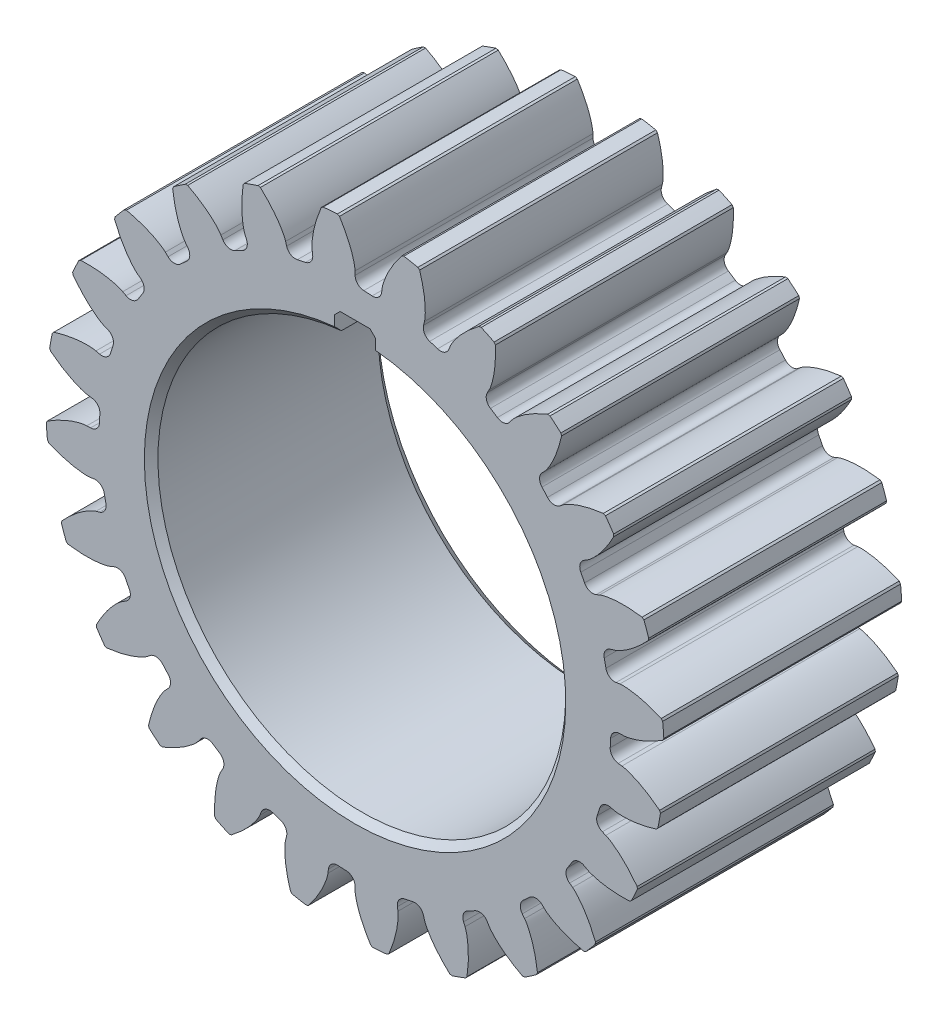
from build123d import *

# Parameters (mm, degrees)
SKETCH1_R                    = 37.625
BOSS_EXTRUDE1_DEPTH          = 35
BOSS_EXTRUDE2_DEPTH          = 35
CHAMFER1_SIZE                = 0.2
CIRPATTERN1_COUNT            = 24
CHAMFER1_OF_CIRPATTERN1_SIZE = 0.2
CUT_EXTRUDE1_DEPTH           = 35
CHAMFER2_SIZE                = 1
CHAMFER3_SIZE                = 1.6
CHAMFER4_SIZE                = 0.8


with BuildPart() as part:
    # Sketch1 → Boss-Extrude1 (new body)
    with BuildSketch(Plane.XY):
        Circle(SKETCH1_R)
    extrude(amount=BOSS_EXTRUDE1_DEPTH)

    # Sketch2 → Boss-Extrude2 (add)
    with BuildSketch(Plane.XY):
        with BuildLine():
            Line((39.4671, 0), (38.912317076, -0.008216426))
            ThreePointArc((38.912317076, -0.008216426), (38.000796603, -0.388472211), (37.602797274, -1.292386237))
            ThreePointArc((37.602797274, -1.292386237), (37.503596186, 3.020082466), (36.911446591, 7.292855106))
            ThreePointArc((36.911446591, 7.292855106), (37.448959809, 6.464275856), (38.409582275, 6.234779642))
            Line((38.409582275, 6.234779642), (38.9585311, 6.315444315))
            add(Edge.make_bspline(
                [(38.9585311, 6.315444315), (38.972678047, 6.317523123), (39.012450629, 6.322704621), (39.087997947, 6.329935202), (39.211681446, 6.33807843), (39.369801706, 6.34307574), (39.5746409, 6.343348403), (39.816411939, 6.335708833), (40.082432074, 6.31896913), (40.372020808, 6.291755537), (40.660942325, 6.256649221), (40.949040892, 6.214231715), (41.23584592, 6.165309201), (41.582899983, 6.098184264), (41.998464173, 6.006768216), (42.482973762, 5.884052997), (43.030761322, 5.726190055), (43.586701733, 5.545432212), (44.131652408, 5.351268244), (44.617289264, 5.160827267), (44.955266967, 5.020725261), (45.162237069, 4.931127491), (45.235496411, 4.898965653)],
                knots=[0, 0, 0, 0, 0, 0.005376749, 0.015083688, 0.02853182, 0.04661014, 0.064854849, 0.092110525, 0.119476176, 0.146842496, 0.174208854, 0.201574956, 0.228941013, 0.256307345, 0.307035032, 0.361767352, 0.416499661, 0.471231937, 0.525964282, 0.580696616, 0.610620377, 0.610620377, 0.610620377, 0.610620377, 0.610620377], degree=4))
            ThreePointArc((45.235496411, 4.898965653), (45.353186086, 3.65219275), (45.436518988, 2.402653171))
            add(Edge.make_bspline(
                [(39.4671, 0), (39.481397298, 0.000211745), (39.521486507, 0.001461342), (39.597217354, 0.006412861), (39.720610143, 0.018166145), (39.877492541, 0.038535309), (40.079735829, 0.071044107), (40.317168963, 0.11727294), (40.577082538, 0.176364932), (40.858584999, 0.249567249), (41.138165863, 0.330453816), (41.41576446, 0.418425677), (41.691045268, 0.512611732), (42.022886035, 0.634406582), (42.418467099, 0.791142382), (42.877096712, 0.989806535), (43.392564635, 1.233291113), (43.912416757, 1.500680173), (44.419275535, 1.779544052), (44.868180552, 2.04524164), (45.179384274, 2.237620804), (45.36935013, 2.359182957), (45.436518988, 2.402653171)],
                knots=[0, 0, 0, 0, 0, 0.005376749, 0.015083688, 0.02853182, 0.04661014, 0.064854849, 0.092110525, 0.119476176, 0.146842496, 0.174208854, 0.201574956, 0.228941013, 0.256307345, 0.307035032, 0.361767352, 0.416499661, 0.471231937, 0.525964282, 0.580696616, 0.610620377, 0.610620377, 0.610620377, 0.610620377, 0.610620377], degree=4))
        make_face()
    boss_extrude2 = extrude(amount=BOSS_EXTRUDE2_DEPTH)

    # Chamfer1
    chamfer1_edges = [part.edges().sort_by_distance(p)[0] for p in [
        (45.436518988, 2.402653171, 17.5),
        (45.235496411, 4.898965653, 17.5),
    ]]
    chamfer(chamfer1_edges, length=CHAMFER1_SIZE)

    # CirPattern1: Boss-Extrude2 ×24 about axis
    cirpattern1_axis = Axis((0, 0, 35), (0, 0, -1))
    for i in range(1, CIRPATTERN1_COUNT):
        add(boss_extrude2.rotate(cirpattern1_axis, i * 360 / CIRPATTERN1_COUNT))

    # Chamfer1 of CirPattern1
    chamfer1_of_cirpattern1_edges = [part.edges().sort_by_distance(p)[0] for p in [
        (44.510159546, -9.439051708, 17.5),
        (44.96207986, -6.97577054, 17.5),
        (40.550506288, -20.637500812, 17.5),
        (41.624571871, -18.375119498, 17.5),
        (33.82740304, -30.42953834, 17.5),
        (35.450418096, -28.522234428, 17.5),
        (24.799018176, -38.147853118, 17.5),
        (26.860376913, -36.725606218, 17.5),
        (14.080621206, -43.266454748, 17.5),
        (16.439845432, -42.426188636, 17.5),
        (2.402653171, -45.436518988, 17.5),
        (4.898965653, -45.235496411, 17.5),
        (-9.439051708, -44.510159546, 17.5),
        (-6.97577054, -44.96207986, 17.5),
        (-20.637500812, -40.550506288, 17.5),
        (-18.375119498, -41.624571871, 17.5),
        (-30.42953834, -33.82740304, 17.5),
        (-28.522234428, -35.450418096, 17.5),
        (-38.147853118, -24.799018176, 17.5),
        (-36.725606218, -26.860376913, 17.5),
        (-43.266454748, -14.080621206, 17.5),
        (-42.426188636, -16.439845432, 17.5),
        (-45.436518988, -2.402653171, 17.5),
        (-45.235496411, -4.898965653, 17.5),
        (-44.510159546, 9.439051708, 17.5),
        (-44.96207986, 6.97577054, 17.5),
        (-40.550506288, 20.637500812, 17.5),
        (-41.624571871, 18.375119498, 17.5),
        (-33.82740304, 30.42953834, 17.5),
        (-35.450418096, 28.522234428, 17.5),
        (-24.799018176, 38.147853118, 17.5),
        (-26.860376913, 36.725606218, 17.5),
        (-14.080621206, 43.266454748, 17.5),
        (-16.439845432, 42.426188636, 17.5),
        (-2.402653171, 45.436518988, 17.5),
        (-4.898965653, 45.235496411, 17.5),
        (9.439051708, 44.510159546, 17.5),
        (6.97577054, 44.96207986, 17.5),
        (20.637500812, 40.550506288, 17.5),
        (18.375119498, 41.624571871, 17.5),
        (30.42953834, 33.82740304, 17.5),
        (28.522234428, 35.450418096, 17.5),
        (38.147853118, 24.799018176, 17.5),
        (36.725606218, 26.860376913, 17.5),
        (43.266454748, 14.080621206, 17.5),
        (42.426188636, 16.439845432, 17.5),
    ]]
    chamfer(chamfer1_of_cirpattern1_edges, length=CHAMFER1_OF_CIRPATTERN1_SIZE)

    # Sketch3 → Cut-Extrude1 (cut)
    with BuildSketch(Plane.XY):
        with BuildLine():
            Line((3, 29.849623113), (3, 33.2))
            Line((3, 33.2), (-3, 33.2))
            Line((-3, 33.2), (-3, 29.849623113))
            ThreePointArc((-3, 29.849623113), (0, -30), (3, 29.849623113))
        make_face()
    extrude(amount=CUT_EXTRUDE1_DEPTH, mode=Mode.SUBTRACT)

    # Chamfer2
    chamfer2_edges = [part.edges().sort_by_distance(p)[0] for p in [
        (0, -30, 35),
    ]]
    chamfer(chamfer2_edges, length=CHAMFER2_SIZE)

    # Chamfer3
    chamfer3_edges = [part.edges().sort_by_distance(p)[0] for p in [
        (0, -30, 0),
    ]]
    chamfer(chamfer3_edges, length=CHAMFER3_SIZE)

    # Chamfer4
    chamfer4_edges = [part.edges().sort_by_distance(p)[0] for p in [
        (3, 33.2, 17.5),
        (-3, 33.2, 17.5),
    ]]
    chamfer(chamfer4_edges, length=CHAMFER4_SIZE)


solid = part.part
